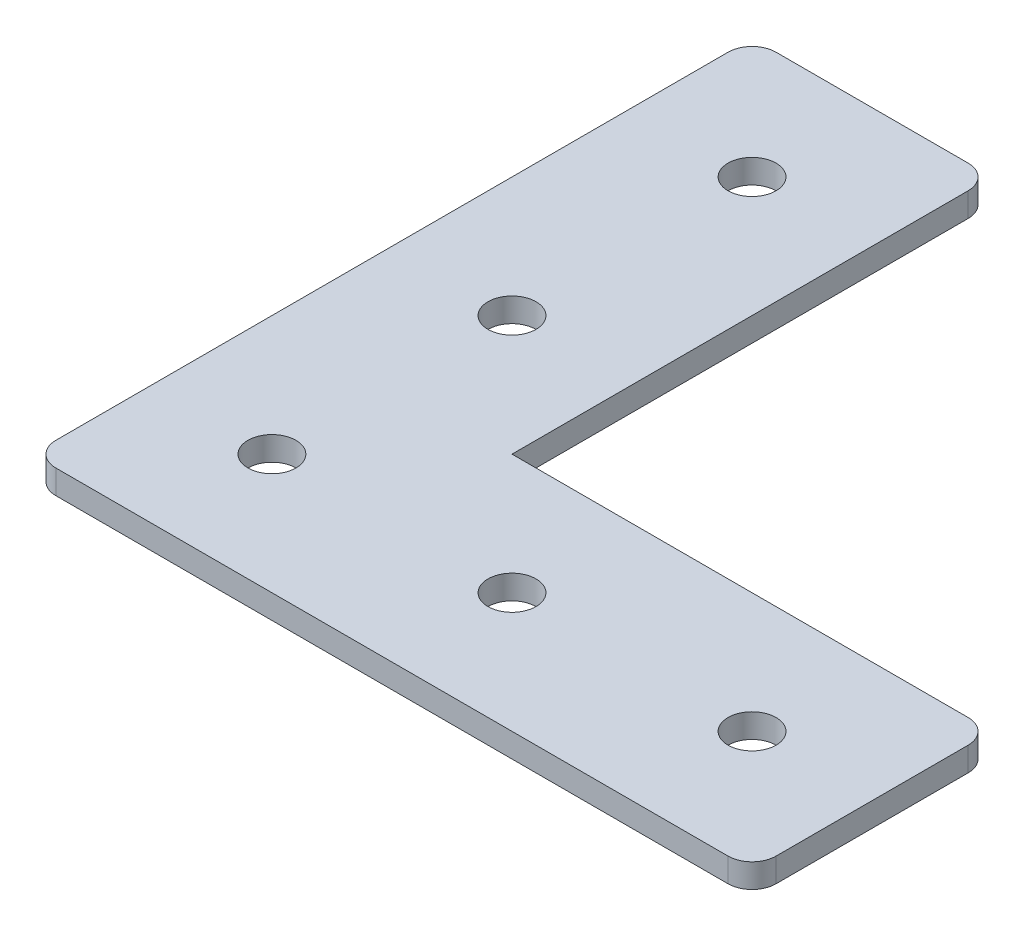
from build123d import *

# Parameters (mm, degrees)
SKETCH1_R           = 2.54
BOSS_EXTRUDE1_DEPTH = 2.54
FILLET1_R           = 2.54


with BuildPart() as part:
    # Sketch1 → Boss-Extrude1 (new body)
    with BuildSketch(Plane(origin=(0, 0, 0), x_dir=(1, 0, 0), z_dir=(0, 1, 0))):
        Polygon((25.4, 76.2), (25.4, 25.4), (76.2, 25.4), (76.2, 0), (0, 0), (0, 76.2), align=None)
        with Locations((12.7, 12.7)):
            Circle(SKETCH1_R, mode=Mode.SUBTRACT)
        with Locations((38.1, 12.7)):
            Circle(SKETCH1_R, mode=Mode.SUBTRACT)
        with Locations((63.5, 12.7)):
            Circle(SKETCH1_R, mode=Mode.SUBTRACT)
        with Locations((12.7, 38.1)):
            Circle(SKETCH1_R, mode=Mode.SUBTRACT)
        with Locations((12.7, 63.5)):
            Circle(SKETCH1_R, mode=Mode.SUBTRACT)
    extrude(amount=BOSS_EXTRUDE1_DEPTH)

    # Fillet1
    fillet1_edges = [part.edges().sort_by_distance(p)[0] for p in [
        (0, 1.27, -76.2),
        (25.4, 1.27, -76.2),
        (76.2, 1.27, -25.4),
        (76.2, 1.27, 0),
        (0, 1.27, 0),
    ]]
    fillet(fillet1_edges, radius=FILLET1_R)


solid = part.part
